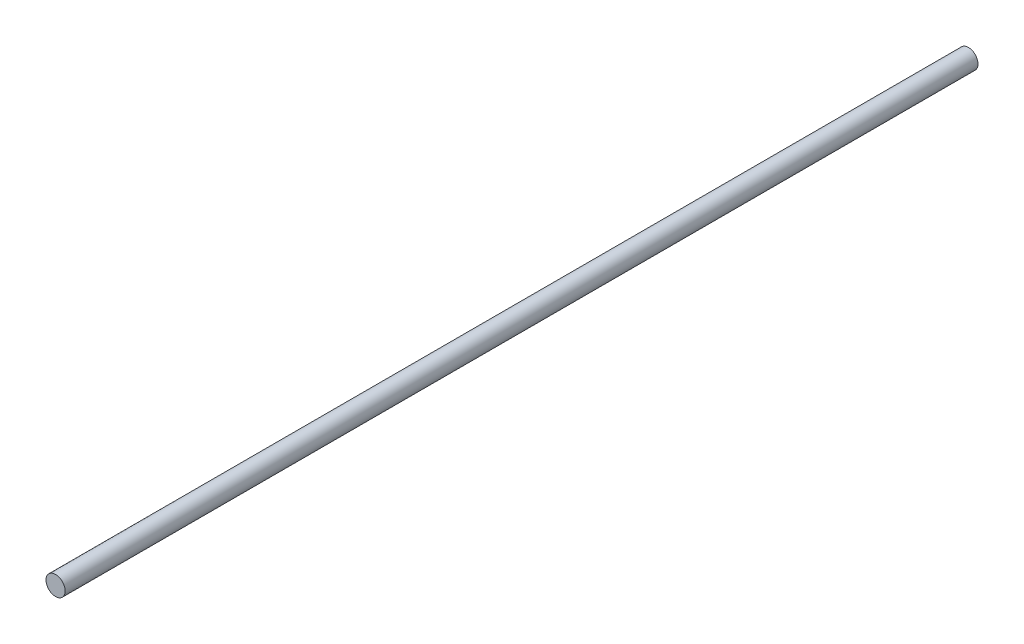
from build123d import *

# Parameters (mm, degrees)
SKETCH1_R           = 4
BOSS_EXTRUDE1_DEPTH = 381


with BuildPart() as part:
    # Sketch1 → Boss-Extrude1 (new body)
    with BuildSketch(Plane.XY):
        Circle(SKETCH1_R)
    extrude(amount=BOSS_EXTRUDE1_DEPTH)


solid = part.part
